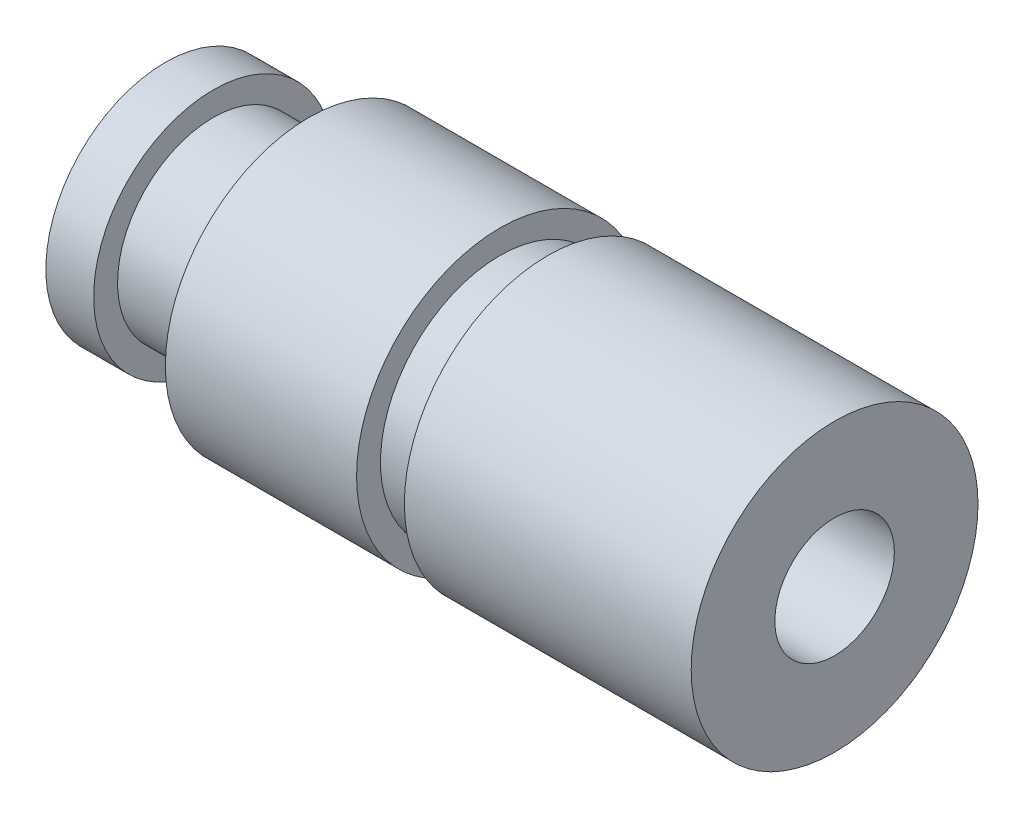
from build123d import *

# Parameters (mm, degrees)
TROU_TARAUD_M31_D       = 2.5
TROU_TARAUD_M31_DEPTH   = 8.5
TROU_TARAUD_M31_TIP     = 0.751075774
ESQUISSE4_R             = 3
ESQUISSE4_R_2           = 2.5
ENL_V_MAT_EXTRU_1_DEPTH = 0.5


with BuildPart() as part:
    # Esquisse1 → Révolution1 (revolve)
    with BuildSketch(Plane.XY):
        Polygon((0, 0), (0, 2.5), (1, 2.5), (1, 2), (3, 2), (3, 3), (14, 3), (14, 0), align=None)
    revolve(axis=Axis((14, 0, 0), (-1, 0, 0)))

    # Trou taraudé M31
    with Locations(Plane(origin=(14, 0, 0), x_dir=(0, 0, -1), z_dir=(1, 0, 0))):
        with Locations((0, 0)):
            Hole(TROU_TARAUD_M31_D / 2, depth=TROU_TARAUD_M31_DEPTH)
            with Locations((0, 0, -(TROU_TARAUD_M31_DEPTH + TROU_TARAUD_M31_TIP / 2))):  # 118° drill point
                Cone(0, TROU_TARAUD_M31_D / 2, TROU_TARAUD_M31_TIP, mode=Mode.SUBTRACT)

    # Esquisse4 → Enlèv. mat.-Extru.1 (cut, symmetric)
    with BuildSketch(Plane.ZY.offset(-7.5)):
        with Locations(Location((0, 0, 0), (0, 0, 90))):  # turned: the seam where the file's is
            Circle(ESQUISSE4_R)
        with Locations(Location((0, 0, 0), (0, 0, 90))):  # turned: the seam where the file's is
            Circle(ESQUISSE4_R_2, mode=Mode.SUBTRACT)
    extrude(amount=ENL_V_MAT_EXTRU_1_DEPTH, both=True, mode=Mode.SUBTRACT)


solid = part.part
